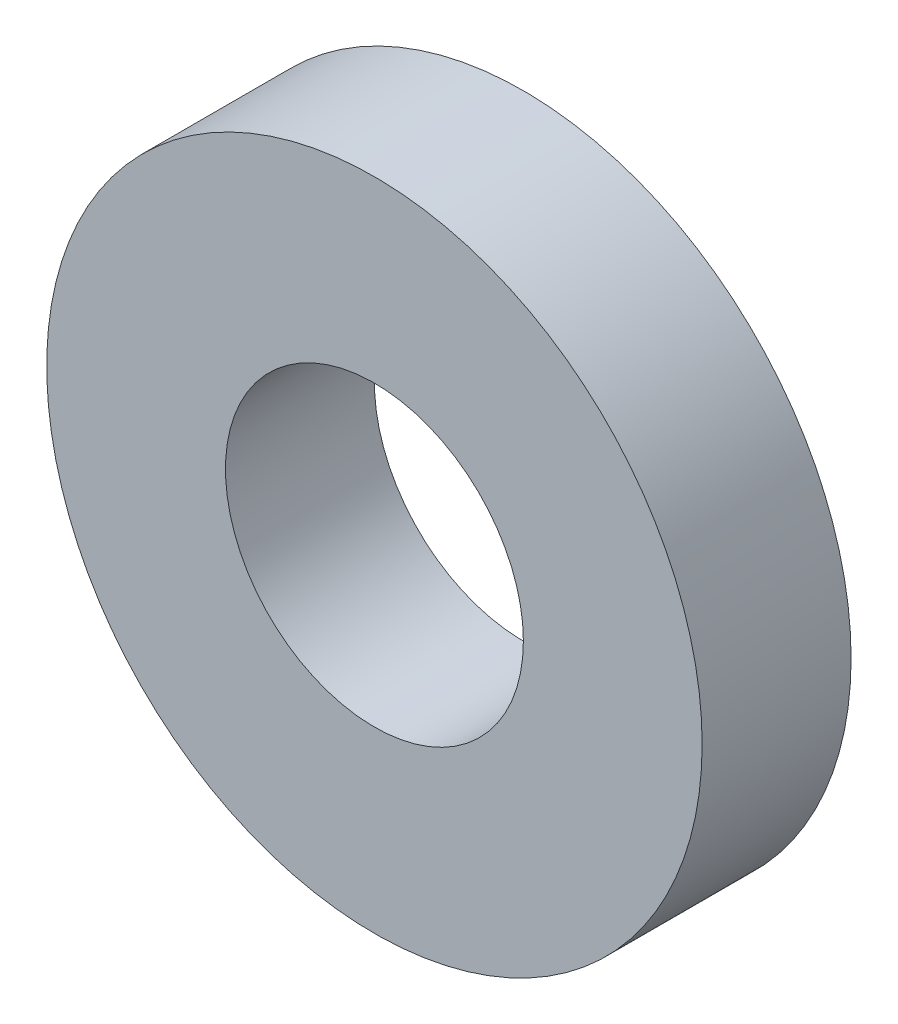
from build123d import *

# Parameters (mm, degrees)
SKETCH1_R           = 13.2
SKETCH1_R_2         = 6
BOSS_EXTRUDE1_DEPTH = 6
SKETCH3_R           = 13.2
SKETCH3_R_2         = 6
BOSS_EXTRUDE2_DEPTH = 6


with BuildPart() as part:
    # Sketch1 → Boss-Extrude1 (new body)
    with BuildSketch(Plane.XY):
        Circle(SKETCH1_R)
        Circle(SKETCH1_R_2, mode=Mode.SUBTRACT)
    extrude(amount=BOSS_EXTRUDE1_DEPTH)

    # Sketch3 → Boss-Extrude2 (add)
    with BuildSketch(Plane.XY):
        Circle(SKETCH3_R)
        Circle(SKETCH3_R_2, mode=Mode.SUBTRACT)
    extrude(amount=BOSS_EXTRUDE2_DEPTH)


solid = part.part
